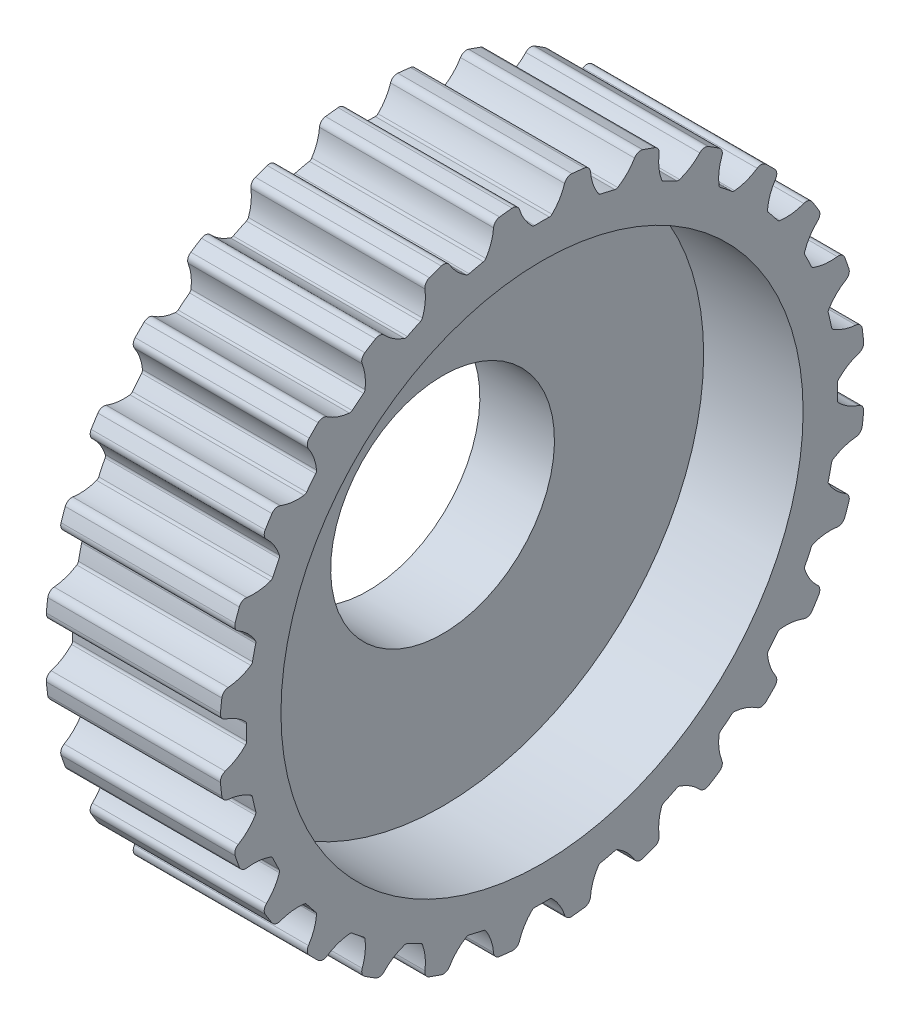
from build123d import *

# Parameters (mm, degrees)
HOLE_WIZARD_1_D          = 9
HOLE_WIZARD_1_DEPTH      = 11
SKETCH_4_R               = 17.99
CUT_EXTRUDE_1_DEPTH      = 7
SKETCH_5_W               = 11.065796971
SKETCH_5_H               = 31.539761408
SKETCH_5_W_2             = 13.395438439
CUT_EXTRUDE_2_DEPTH      = 16
CUT_EXTRUDE_2_DEPTH_BACK = 16
SKETCH_6_R               = 10.5
CUT_EXTRUDE_3_DEPTH      = 4


with BuildPart() as part:
    # 草图1 → 旋转1 (revolve)
    with BuildSketch(Plane.XY):
        Polygon((0, 0), (0, 10), (1, 10), (1, 12.858347502), (0.495496297, 14.741180955), (1.461422123, 15), (2, 12.99), (9, 12.99), (9.538577877, 15), (10.504503703, 14.741180955), (10, 12.858347502), (10, 10), (11, 10), (11, 0), align=None)
    revolve(axis=Axis((11, 0, 0), (-1, 0, 0)))

    # 孔1
    with Locations(Plane(origin=(11, 0, 0), x_dir=(0, 0, -1), z_dir=(1, 0, 0))):
        with Locations((0, 0)):
            Hole(HOLE_WIZARD_1_D / 2, depth=HOLE_WIZARD_1_DEPTH)

    # 草图4 → 切除-拉伸1 (cut)
    with BuildSketch(Plane(origin=(2, 0, 0), x_dir=(0, 0, -1), z_dir=(1, 0, 0))):
        Circle(SKETCH_4_R)
        with BuildLine():
            ThreePointArc((-12.934335103, 1.201280746), (-12.888789145, 1.020492007), (-12.739828866, 0.908376719))
            ThreePointArc((-12.739828866, 0.908376719), (-12.297942775, 0.706183335), (-11.918804359, 0.402210404))
            ThreePointArc((-11.918804359, 0.402210404), (-11.886657302, 0.352337477), (-11.876364008, 0.293901271))
            ThreePointArc((-11.876364008, 0.293901271), (-11.88, 0), (-11.876364008, -0.293901271))
            ThreePointArc((-11.876364008, -0.293901271), (-11.886657302, -0.352337477), (-11.918804359, -0.402210404))
            ThreePointArc((-11.918804359, -0.402210404), (-12.297942775, -0.706183335), (-12.739828866, -0.908376719))
            ThreePointArc((-12.739828866, -0.908376719), (-12.888789145, -1.020492007), (-12.934335103, -1.201280746))
            ThreePointArc((-12.934335103, -1.201280746), (-12.908321607, -1.454418545), (-12.877354431, -1.706998197))
            ThreePointArc((-12.877354431, -1.706998197), (-12.792721126, -1.873119256), (-12.622547594, -1.9492768))
            ThreePointArc((-12.622547594, -1.9492768), (-12.146748249, -2.048071867), (-11.709475284, -2.260057328))
            ThreePointArc((-11.709475284, -2.260057328), (-11.667036451, -2.301526443), (-11.643997952, -2.356207058))
            ThreePointArc((-11.643997952, -2.356207058), (-11.582143597, -2.643548695), (-11.513199581, -2.929272164))
            ThreePointArc((-11.513199581, -2.929272164), (-11.510231522, -2.988533726), (-11.530474814, -3.044309627))
            ThreePointArc((-11.530474814, -3.044309627), (-11.832467099, -3.425027557), (-12.218281922, -3.720480436))
            ThreePointArc((-12.218281922, -3.720480436), (-12.338559457, -3.86293154), (-12.342734204, -4.049322457))
            ThreePointArc((-12.342734204, -4.049322457), (-12.261044461, -4.290325015), (-12.174649437, -4.529681124))
            ThreePointArc((-12.174649437, -4.529681124), (-12.055172652, -4.672804499), (-11.872319078, -4.70918544))
            ThreePointArc((-11.872319078, -4.70918544), (-11.386465046, -4.699628195), (-10.912984224, -4.808996348))
            ThreePointArc((-10.912984224, -4.808996348), (-10.862381675, -4.839982218), (-10.827753217, -4.888165327))
            ThreePointArc((-10.827753217, -4.888165327), (-10.703510151, -5.154538821), (-10.572715252, -5.417757118))
            ThreePointArc((-10.572715252, -5.417757118), (-10.556634671, -5.474872414), (-10.563959116, -5.533754454))
            ThreePointArc((-10.563959116, -5.533754454), (-10.773662114, -5.972126595), (-11.084059304, -6.346023728))
            ThreePointArc((-11.084059304, -6.346023728), (-11.169622877, -6.511667555), (-11.132217073, -6.694314232))
            ThreePointArc((-11.132217073, -6.694314232), (-10.998947348, -6.911096674), (-10.861456683, -7.125226924))
            ThreePointArc((-10.861456683, -7.125226924), (-10.713127484, -7.238175812), (-10.526762909, -7.232955859))
            ThreePointArc((-10.526762909, -7.232955859), (-10.055216939, -7.11552554), (-9.569270566, -7.116792211))
            ThreePointArc((-9.569270566, -7.116792211), (-9.513041724, -7.135741074), (-9.468559724, -7.175010575))
            ThreePointArc((-9.468559724, -7.175010575), (-9.288158012, -7.407058846), (-9.102070833, -7.634573108))
            ThreePointArc((-9.102070833, -7.634573108), (-9.073684076, -7.686678138), (-9.067722396, -7.745713725))
            ThreePointArc((-9.067722396, -7.745713725), (-9.174620723, -8.219758268), (-9.394035669, -8.653350892))
            ThreePointArc((-9.394035669, -8.653350892), (-9.440594765, -8.833881369), (-9.363484094, -9.003625138))
            ThreePointArc((-9.363484094, -9.003625138), (-9.185317088, -9.185317088), (-9.003625138, -9.363484094))
            ThreePointArc((-9.003625138, -9.363484094), (-8.833881369, -9.440594765), (-8.653350892, -9.394035669))
            ThreePointArc((-8.653350892, -9.394035669), (-8.219758268, -9.174620723), (-7.745713725, -9.067722396))
            ThreePointArc((-7.745713725, -9.067722396), (-7.686678138, -9.073684076), (-7.634573108, -9.102070833))
            ThreePointArc((-7.634573108, -9.102070833), (-7.407058846, -9.288158012), (-7.175010575, -9.468559724))
            ThreePointArc((-7.175010575, -9.468559724), (-7.135741074, -9.513041724), (-7.116792211, -9.569270566))
            ThreePointArc((-7.116792211, -9.569270566), (-7.11552554, -10.055216939), (-7.232955859, -10.526762909))
            ThreePointArc((-7.232955859, -10.526762909), (-7.238175812, -10.713127484), (-7.125226924, -10.861456683))
            ThreePointArc((-7.125226924, -10.861456683), (-6.911096674, -10.998947348), (-6.694314232, -11.132217073))
            ThreePointArc((-6.694314232, -11.132217073), (-6.511667555, -11.169622877), (-6.346023728, -11.084059304))
            ThreePointArc((-6.346023728, -11.084059304), (-5.972126595, -10.773662114), (-5.533754454, -10.563959116))
            ThreePointArc((-5.533754454, -10.563959116), (-5.474872414, -10.556634671), (-5.417757118, -10.572715252))
            ThreePointArc((-5.417757118, -10.572715252), (-5.154538821, -10.703510151), (-4.888165327, -10.827753217))
            ThreePointArc((-4.888165327, -10.827753217), (-4.839982218, -10.862381675), (-4.808996348, -10.912984224))
            ThreePointArc((-4.808996348, -10.912984224), (-4.699628195, -11.386465046), (-4.70918544, -11.872319078))
            ThreePointArc((-4.70918544, -11.872319078), (-4.672804499, -12.055172652), (-4.529681124, -12.174649437))
            ThreePointArc((-4.529681124, -12.174649437), (-4.290325015, -12.261044461), (-4.049322457, -12.342734204))
            ThreePointArc((-4.049322457, -12.342734204), (-3.86293154, -12.338559457), (-3.720480436, -12.218281922))
            ThreePointArc((-3.720480436, -12.218281922), (-3.425027557, -11.832467099), (-3.044309627, -11.530474814))
            ThreePointArc((-3.044309627, -11.530474814), (-2.988533726, -11.510231522), (-2.929272164, -11.513199581))
            ThreePointArc((-2.929272164, -11.513199581), (-2.643548695, -11.582143597), (-2.356207058, -11.643997952))
            ThreePointArc((-2.356207058, -11.643997952), (-2.301526443, -11.667036451), (-2.260057328, -11.709475284))
            ThreePointArc((-2.260057328, -11.709475284), (-2.048071867, -12.146748249), (-1.9492768, -12.622547594))
            ThreePointArc((-1.9492768, -12.622547594), (-1.873119256, -12.792721126), (-1.706998197, -12.877354431))
            ThreePointArc((-1.706998197, -12.877354431), (-1.454418545, -12.908321607), (-1.201280746, -12.934335103))
            ThreePointArc((-1.201280746, -12.934335103), (-1.020492007, -12.888789145), (-0.908376719, -12.739828866))
            ThreePointArc((-0.908376719, -12.739828866), (-0.706183335, -12.297942775), (-0.402210404, -11.918804359))
            ThreePointArc((-0.402210404, -11.918804359), (-0.352337477, -11.886657302), (-0.293901271, -11.876364008))
            ThreePointArc((-0.293901271, -11.876364008), (0, -11.88), (0.293901271, -11.876364008))
            ThreePointArc((0.293901271, -11.876364008), (0.352337477, -11.886657302), (0.402210404, -11.918804359))
            ThreePointArc((0.402210404, -11.918804359), (0.706183335, -12.297942775), (0.908376719, -12.739828866))
            ThreePointArc((0.908376719, -12.739828866), (1.020492007, -12.888789145), (1.201280746, -12.934335103))
            ThreePointArc((1.201280746, -12.934335103), (1.454418545, -12.908321607), (1.706998197, -12.877354431))
            ThreePointArc((1.706998197, -12.877354431), (1.873119256, -12.792721126), (1.9492768, -12.622547594))
            ThreePointArc((1.9492768, -12.622547594), (2.048071867, -12.146748249), (2.260057328, -11.709475284))
            ThreePointArc((2.260057328, -11.709475284), (2.301526443, -11.667036451), (2.356207058, -11.643997952))
            ThreePointArc((2.356207058, -11.643997952), (2.643548695, -11.582143597), (2.929272164, -11.513199581))
            ThreePointArc((2.929272164, -11.513199581), (2.988533726, -11.510231522), (3.044309627, -11.530474814))
            ThreePointArc((3.044309627, -11.530474814), (3.425027557, -11.832467099), (3.720480436, -12.218281922))
            ThreePointArc((3.720480436, -12.218281922), (3.86293154, -12.338559457), (4.049322457, -12.342734204))
            ThreePointArc((4.049322457, -12.342734204), (4.290325015, -12.261044461), (4.529681124, -12.174649437))
            ThreePointArc((4.529681124, -12.174649437), (4.672804499, -12.055172652), (4.70918544, -11.872319078))
            ThreePointArc((4.70918544, -11.872319078), (4.699628195, -11.386465046), (4.808996348, -10.912984224))
            ThreePointArc((4.808996348, -10.912984224), (4.839982218, -10.862381675), (4.888165327, -10.827753217))
            ThreePointArc((4.888165327, -10.827753217), (5.154538821, -10.703510151), (5.417757118, -10.572715252))
            ThreePointArc((5.417757118, -10.572715252), (5.474872414, -10.556634671), (5.533754454, -10.563959116))
            ThreePointArc((5.533754454, -10.563959116), (5.972126595, -10.773662114), (6.346023728, -11.084059304))
            ThreePointArc((6.346023728, -11.084059304), (6.511667555, -11.169622877), (6.694314232, -11.132217073))
            ThreePointArc((6.694314232, -11.132217073), (6.911096674, -10.998947348), (7.125226924, -10.861456683))
            ThreePointArc((7.125226924, -10.861456683), (7.238175812, -10.713127484), (7.232955859, -10.526762909))
            ThreePointArc((7.232955859, -10.526762909), (7.11552554, -10.055216939), (7.116792211, -9.569270566))
            ThreePointArc((7.116792211, -9.569270566), (7.135741074, -9.513041724), (7.175010575, -9.468559724))
            ThreePointArc((7.175010575, -9.468559724), (7.407058846, -9.288158012), (7.634573108, -9.102070833))
            ThreePointArc((7.634573108, -9.102070833), (7.686678138, -9.073684076), (7.745713725, -9.067722396))
            ThreePointArc((7.745713725, -9.067722396), (8.219758268, -9.174620723), (8.653350892, -9.394035669))
            ThreePointArc((8.653350892, -9.394035669), (8.833881369, -9.440594765), (9.003625138, -9.363484094))
            ThreePointArc((9.003625138, -9.363484094), (9.185317088, -9.185317088), (9.363484094, -9.003625138))
            ThreePointArc((9.363484094, -9.003625138), (9.440594765, -8.833881369), (9.394035669, -8.653350892))
            ThreePointArc((9.394035669, -8.653350892), (9.174620723, -8.219758268), (9.067722396, -7.745713725))
            ThreePointArc((9.067722396, -7.745713725), (9.073684076, -7.686678138), (9.102070833, -7.634573108))
            ThreePointArc((9.102070833, -7.634573108), (9.288158012, -7.407058846), (9.468559724, -7.175010575))
            ThreePointArc((9.468559724, -7.175010575), (9.513041724, -7.135741074), (9.569270566, -7.116792211))
            ThreePointArc((9.569270566, -7.116792211), (10.055216939, -7.11552554), (10.526762909, -7.232955859))
            ThreePointArc((10.526762909, -7.232955859), (10.713127484, -7.238175812), (10.861456683, -7.125226924))
            ThreePointArc((10.861456683, -7.125226924), (10.998947348, -6.911096674), (11.132217073, -6.694314232))
            ThreePointArc((11.132217073, -6.694314232), (11.169622877, -6.511667555), (11.084059304, -6.346023728))
            ThreePointArc((11.084059304, -6.346023728), (10.773662114, -5.972126595), (10.563959116, -5.533754454))
            ThreePointArc((10.563959116, -5.533754454), (10.556634671, -5.474872414), (10.572715252, -5.417757118))
            ThreePointArc((10.572715252, -5.417757118), (10.703510151, -5.154538821), (10.827753217, -4.888165327))
            ThreePointArc((10.827753217, -4.888165327), (10.862381675, -4.839982218), (10.912984224, -4.808996348))
            ThreePointArc((10.912984224, -4.808996348), (11.386465046, -4.699628195), (11.872319078, -4.70918544))
            ThreePointArc((11.872319078, -4.70918544), (12.055172652, -4.672804499), (12.174649437, -4.529681124))
            ThreePointArc((12.174649437, -4.529681124), (12.261044461, -4.290325015), (12.342734204, -4.049322457))
            ThreePointArc((12.342734204, -4.049322457), (12.338559457, -3.86293154), (12.218281922, -3.720480436))
            ThreePointArc((12.218281922, -3.720480436), (11.832467099, -3.425027557), (11.530474814, -3.044309627))
            ThreePointArc((11.530474814, -3.044309627), (11.510231522, -2.988533726), (11.513199581, -2.929272164))
            ThreePointArc((11.513199581, -2.929272164), (11.582143597, -2.643548695), (11.643997952, -2.356207058))
            ThreePointArc((11.643997952, -2.356207058), (11.667036451, -2.301526443), (11.709475284, -2.260057328))
            ThreePointArc((11.709475284, -2.260057328), (12.146748249, -2.048071867), (12.622547594, -1.9492768))
            ThreePointArc((12.622547594, -1.9492768), (12.792721126, -1.873119256), (12.877354431, -1.706998197))
            ThreePointArc((12.877354431, -1.706998197), (12.908321607, -1.454418545), (12.934335103, -1.201280746))
            ThreePointArc((12.934335103, -1.201280746), (12.888789145, -1.020492007), (12.739828866, -0.908376719))
            ThreePointArc((12.739828866, -0.908376719), (12.297942775, -0.706183335), (11.918804359, -0.402210404))
            ThreePointArc((11.918804359, -0.402210404), (11.886657302, -0.352337477), (11.876364008, -0.293901271))
            ThreePointArc((11.876364008, -0.293901271), (11.88, 0), (11.876364008, 0.293901271))
            ThreePointArc((11.876364008, 0.293901271), (11.886657302, 0.352337477), (11.918804359, 0.402210404))
            ThreePointArc((11.918804359, 0.402210404), (12.297942775, 0.706183335), (12.739828866, 0.908376719))
            ThreePointArc((12.739828866, 0.908376719), (12.888789145, 1.020492007), (12.934335103, 1.201280746))
            ThreePointArc((12.934335103, 1.201280746), (12.908321607, 1.454418545), (12.877354431, 1.706998197))
            ThreePointArc((12.877354431, 1.706998197), (12.792721126, 1.873119256), (12.622547594, 1.9492768))
            ThreePointArc((12.622547594, 1.9492768), (12.146748249, 2.048071867), (11.709475284, 2.260057328))
            ThreePointArc((11.709475284, 2.260057328), (11.667036451, 2.301526443), (11.643997952, 2.356207058))
            ThreePointArc((11.643997952, 2.356207058), (11.582143597, 2.643548695), (11.513199581, 2.929272164))
            ThreePointArc((11.513199581, 2.929272164), (11.510231522, 2.988533726), (11.530474814, 3.044309627))
            ThreePointArc((11.530474814, 3.044309627), (11.832467099, 3.425027557), (12.218281922, 3.720480436))
            ThreePointArc((12.218281922, 3.720480436), (12.338559457, 3.86293154), (12.342734204, 4.049322457))
            ThreePointArc((12.342734204, 4.049322457), (12.261044461, 4.290325015), (12.174649437, 4.529681124))
            ThreePointArc((12.174649437, 4.529681124), (12.055172652, 4.672804499), (11.872319078, 4.70918544))
            ThreePointArc((11.872319078, 4.70918544), (11.386465046, 4.699628195), (10.912984224, 4.808996348))
            ThreePointArc((10.912984224, 4.808996348), (10.862381675, 4.839982218), (10.827753217, 4.888165327))
            ThreePointArc((10.827753217, 4.888165327), (10.703510151, 5.154538821), (10.572715252, 5.417757118))
            ThreePointArc((10.572715252, 5.417757118), (10.556634671, 5.474872414), (10.563959116, 5.533754454))
            ThreePointArc((10.563959116, 5.533754454), (10.773662114, 5.972126595), (11.084059304, 6.346023728))
            ThreePointArc((11.084059304, 6.346023728), (11.169622877, 6.511667555), (11.132217073, 6.694314232))
            ThreePointArc((11.132217073, 6.694314232), (10.998947348, 6.911096674), (10.861456683, 7.125226924))
            ThreePointArc((10.861456683, 7.125226924), (10.713127484, 7.238175812), (10.526762909, 7.232955859))
            ThreePointArc((10.526762909, 7.232955859), (10.055216939, 7.11552554), (9.569270566, 7.116792211))
            ThreePointArc((9.569270566, 7.116792211), (9.513041724, 7.135741074), (9.468559724, 7.175010575))
            ThreePointArc((9.468559724, 7.175010575), (9.288158012, 7.407058846), (9.102070833, 7.634573108))
            ThreePointArc((9.102070833, 7.634573108), (9.073684076, 7.686678138), (9.067722396, 7.745713725))
            ThreePointArc((9.067722396, 7.745713725), (9.174620723, 8.219758268), (9.394035669, 8.653350892))
            ThreePointArc((9.394035669, 8.653350892), (9.440594765, 8.833881369), (9.363484094, 9.003625138))
            ThreePointArc((9.363484094, 9.003625138), (9.185317088, 9.185317088), (9.003625138, 9.363484094))
            ThreePointArc((9.003625138, 9.363484094), (8.833881369, 9.440594765), (8.653350892, 9.394035669))
            ThreePointArc((8.653350892, 9.394035669), (8.219758268, 9.174620723), (7.745713725, 9.067722396))
            ThreePointArc((7.745713725, 9.067722396), (7.686678138, 9.073684076), (7.634573108, 9.102070833))
            ThreePointArc((7.634573108, 9.102070833), (7.407058846, 9.288158012), (7.175010575, 9.468559724))
            ThreePointArc((7.175010575, 9.468559724), (7.135741074, 9.513041724), (7.116792211, 9.569270566))
            ThreePointArc((7.116792211, 9.569270566), (7.11552554, 10.055216939), (7.232955859, 10.526762909))
            ThreePointArc((7.232955859, 10.526762909), (7.238175812, 10.713127484), (7.125226924, 10.861456683))
            ThreePointArc((7.125226924, 10.861456683), (6.911096674, 10.998947348), (6.694314232, 11.132217073))
            ThreePointArc((6.694314232, 11.132217073), (6.511667555, 11.169622877), (6.346023728, 11.084059304))
            ThreePointArc((6.346023728, 11.084059304), (5.972126595, 10.773662114), (5.533754454, 10.563959116))
            ThreePointArc((5.533754454, 10.563959116), (5.474872414, 10.556634671), (5.417757118, 10.572715252))
            ThreePointArc((5.417757118, 10.572715252), (5.154538821, 10.703510151), (4.888165327, 10.827753217))
            ThreePointArc((4.888165327, 10.827753217), (4.839982218, 10.862381675), (4.808996348, 10.912984224))
            ThreePointArc((4.808996348, 10.912984224), (4.699628195, 11.386465046), (4.70918544, 11.872319078))
            ThreePointArc((4.70918544, 11.872319078), (4.672804499, 12.055172652), (4.529681124, 12.174649437))
            ThreePointArc((4.529681124, 12.174649437), (4.290325015, 12.261044461), (4.049322457, 12.342734204))
            ThreePointArc((4.049322457, 12.342734204), (3.86293154, 12.338559457), (3.720480436, 12.218281922))
            ThreePointArc((3.720480436, 12.218281922), (3.425027557, 11.832467099), (3.044309627, 11.530474814))
            ThreePointArc((3.044309627, 11.530474814), (2.988533726, 11.510231522), (2.929272164, 11.513199581))
            ThreePointArc((2.929272164, 11.513199581), (2.643548695, 11.582143597), (2.356207058, 11.643997952))
            ThreePointArc((2.356207058, 11.643997952), (2.301526443, 11.667036451), (2.260057328, 11.709475284))
            ThreePointArc((2.260057328, 11.709475284), (2.048071867, 12.146748249), (1.9492768, 12.622547594))
            ThreePointArc((1.9492768, 12.622547594), (1.873119256, 12.792721126), (1.706998197, 12.877354431))
            ThreePointArc((1.706998197, 12.877354431), (1.454418545, 12.908321607), (1.201280746, 12.934335103))
            ThreePointArc((1.201280746, 12.934335103), (1.020492007, 12.888789145), (0.908376719, 12.739828866))
            ThreePointArc((0.908376719, 12.739828866), (0.706183335, 12.297942775), (0.402210404, 11.918804359))
            ThreePointArc((0.402210404, 11.918804359), (0.352337477, 11.886657302), (0.293901271, 11.876364008))
            ThreePointArc((0.293901271, 11.876364008), (0, 11.88), (-0.293901271, 11.876364008))
            ThreePointArc((-0.293901271, 11.876364008), (-0.352337477, 11.886657302), (-0.402210404, 11.918804359))
            ThreePointArc((-0.402210404, 11.918804359), (-0.706183335, 12.297942775), (-0.908376719, 12.739828866))
            ThreePointArc((-0.908376719, 12.739828866), (-1.020492007, 12.888789145), (-1.201280746, 12.934335103))
            ThreePointArc((-1.201280746, 12.934335103), (-1.454418545, 12.908321607), (-1.706998197, 12.877354431))
            ThreePointArc((-1.706998197, 12.877354431), (-1.873119256, 12.792721126), (-1.9492768, 12.622547594))
            ThreePointArc((-1.9492768, 12.622547594), (-2.048071867, 12.146748249), (-2.260057328, 11.709475284))
            ThreePointArc((-2.260057328, 11.709475284), (-2.301526443, 11.667036451), (-2.356207058, 11.643997952))
            ThreePointArc((-2.356207058, 11.643997952), (-2.643548695, 11.582143597), (-2.929272164, 11.513199581))
            ThreePointArc((-2.929272164, 11.513199581), (-2.988533726, 11.510231522), (-3.044309627, 11.530474814))
            ThreePointArc((-3.044309627, 11.530474814), (-3.425027557, 11.832467099), (-3.720480436, 12.218281922))
            ThreePointArc((-3.720480436, 12.218281922), (-3.86293154, 12.338559457), (-4.049322457, 12.342734204))
            ThreePointArc((-4.049322457, 12.342734204), (-4.290325015, 12.261044461), (-4.529681124, 12.174649437))
            ThreePointArc((-4.529681124, 12.174649437), (-4.672804499, 12.055172652), (-4.70918544, 11.872319078))
            ThreePointArc((-4.70918544, 11.872319078), (-4.699628195, 11.386465046), (-4.808996348, 10.912984224))
            ThreePointArc((-4.808996348, 10.912984224), (-4.839982218, 10.862381675), (-4.888165327, 10.827753217))
            ThreePointArc((-4.888165327, 10.827753217), (-5.154538821, 10.703510151), (-5.417757118, 10.572715252))
            ThreePointArc((-5.417757118, 10.572715252), (-5.474872414, 10.556634671), (-5.533754454, 10.563959116))
            ThreePointArc((-5.533754454, 10.563959116), (-5.972126595, 10.773662114), (-6.346023728, 11.084059304))
            ThreePointArc((-6.346023728, 11.084059304), (-6.511667555, 11.169622877), (-6.694314232, 11.132217073))
            ThreePointArc((-6.694314232, 11.132217073), (-6.911096674, 10.998947348), (-7.125226924, 10.861456683))
            ThreePointArc((-7.125226924, 10.861456683), (-7.238175812, 10.713127484), (-7.232955859, 10.526762909))
            ThreePointArc((-7.232955859, 10.526762909), (-7.11552554, 10.055216939), (-7.116792211, 9.569270566))
            ThreePointArc((-7.116792211, 9.569270566), (-7.135741074, 9.513041724), (-7.175010575, 9.468559724))
            ThreePointArc((-7.175010575, 9.468559724), (-7.407058846, 9.288158012), (-7.634573108, 9.102070833))
            ThreePointArc((-7.634573108, 9.102070833), (-7.686678138, 9.073684076), (-7.745713725, 9.067722396))
            ThreePointArc((-7.745713725, 9.067722396), (-8.219758268, 9.174620723), (-8.653350892, 9.394035669))
            ThreePointArc((-8.653350892, 9.394035669), (-8.833881369, 9.440594765), (-9.003625138, 9.363484094))
            ThreePointArc((-9.003625138, 9.363484094), (-9.185317088, 9.185317088), (-9.363484094, 9.003625138))
            ThreePointArc((-9.363484094, 9.003625138), (-9.440594765, 8.833881369), (-9.394035669, 8.653350892))
            ThreePointArc((-9.394035669, 8.653350892), (-9.174620723, 8.219758268), (-9.067722396, 7.745713725))
            ThreePointArc((-9.067722396, 7.745713725), (-9.073684076, 7.686678138), (-9.102070833, 7.634573108))
            ThreePointArc((-9.102070833, 7.634573108), (-9.288158012, 7.407058846), (-9.468559724, 7.175010575))
            ThreePointArc((-9.468559724, 7.175010575), (-9.513041724, 7.135741074), (-9.569270566, 7.116792211))
            ThreePointArc((-9.569270566, 7.116792211), (-10.055216939, 7.11552554), (-10.526762909, 7.232955859))
            ThreePointArc((-10.526762909, 7.232955859), (-10.713127484, 7.238175812), (-10.861456683, 7.125226924))
            ThreePointArc((-10.861456683, 7.125226924), (-10.998947348, 6.911096674), (-11.132217073, 6.694314232))
            ThreePointArc((-11.132217073, 6.694314232), (-11.169622877, 6.511667555), (-11.084059304, 6.346023728))
            ThreePointArc((-11.084059304, 6.346023728), (-10.773662114, 5.972126595), (-10.563959116, 5.533754454))
            ThreePointArc((-10.563959116, 5.533754454), (-10.556634671, 5.474872414), (-10.572715252, 5.417757118))
            ThreePointArc((-10.572715252, 5.417757118), (-10.703510151, 5.154538821), (-10.827753217, 4.888165327))
            ThreePointArc((-10.827753217, 4.888165327), (-10.862381675, 4.839982218), (-10.912984224, 4.808996348))
            ThreePointArc((-10.912984224, 4.808996348), (-11.386465046, 4.699628195), (-11.872319078, 4.70918544))
            ThreePointArc((-11.872319078, 4.70918544), (-12.055172652, 4.672804499), (-12.174649437, 4.529681124))
            ThreePointArc((-12.174649437, 4.529681124), (-12.261044461, 4.290325015), (-12.342734204, 4.049322457))
            ThreePointArc((-12.342734204, 4.049322457), (-12.338559457, 3.86293154), (-12.218281922, 3.720480436))
            ThreePointArc((-12.218281922, 3.720480436), (-11.832467099, 3.425027557), (-11.530474814, 3.044309627))
            ThreePointArc((-11.530474814, 3.044309627), (-11.510231522, 2.988533726), (-11.513199581, 2.929272164))
            ThreePointArc((-11.513199581, 2.929272164), (-11.582143597, 2.643548695), (-11.643997952, 2.356207058))
            ThreePointArc((-11.643997952, 2.356207058), (-11.667036451, 2.301526443), (-11.709475284, 2.260057328))
            ThreePointArc((-11.709475284, 2.260057328), (-12.146748249, 2.048071867), (-12.622547594, 1.9492768))
            ThreePointArc((-12.622547594, 1.9492768), (-12.792721126, 1.873119256), (-12.877354431, 1.706998197))
            ThreePointArc((-12.877354431, 1.706998197), (-12.908321607, 1.454418545), (-12.934335103, 1.201280746))
        make_face(mode=Mode.SUBTRACT)
    extrude(amount=CUT_EXTRUDE_1_DEPTH, mode=Mode.SUBTRACT)

    # 草图5 → 切除-拉伸2 (cut, two sides)
    with BuildSketch(Plane.XY) as cut_extrude_2_sk:
        with Locations((-3.532898486, 0.112001994)):
            Rectangle(SKETCH_5_W, SKETCH_5_H)
        with Locations((15.69771922, 0.112001994)):
            Rectangle(SKETCH_5_W_2, SKETCH_5_H)
    extrude(amount=CUT_EXTRUDE_2_DEPTH, mode=Mode.SUBTRACT)
    extrude(cut_extrude_2_sk.sketch, amount=-CUT_EXTRUDE_2_DEPTH_BACK, mode=Mode.SUBTRACT)

    # 草图6 → 切除-拉伸3 (cut)
    with BuildSketch(Plane(origin=(9, 0, 0), x_dir=(0, 0, -1), z_dir=(1, 0, 0))):
        Circle(SKETCH_6_R)
    extrude(amount=-CUT_EXTRUDE_3_DEPTH, mode=Mode.SUBTRACT)


solid = part.part
